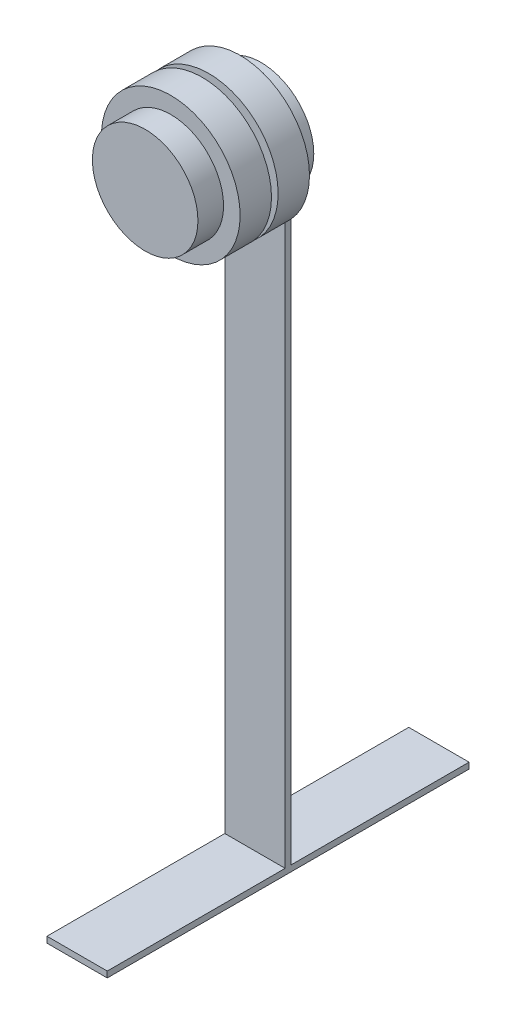
from build123d import *

# Parameters (mm, degrees)
SKETCH1_R                = 22.225
HUB_CENTER_DEPTH         = 25.4
HUB_CENTER_DEPTH_BACK    = 23.4
INNER_START              = 1.397
SKETCH2_R                = 29.21
INNER_BEARING_DEPTH      = 13.208
OUTER_START              = -1.397
SKETCH3_R                = 29.21
OUTER_BEARING_DEPTH      = 13.208
TIRE_ARM_DEPTH           = 2.54
SKETCH5_W                = 25.4
SKETCH5_H                = 152.4
TIRE_CONTACT_PATCH_DEPTH = 2.54


with BuildPart() as part:
    # Sketch1 → Hub Center (new body, two sides)
    with BuildSketch(Plane.XY) as hub_center_sk:
        Circle(SKETCH1_R)
    extrude(amount=HUB_CENTER_DEPTH)
    extrude(hub_center_sk.sketch, amount=-HUB_CENTER_DEPTH_BACK)

    # Sketch2 → Inner Bearing (add)
    with BuildSketch(Plane.XY.offset(INNER_START)):
        Circle(SKETCH2_R)
    extrude(amount=INNER_BEARING_DEPTH)

    # Sketch3 → Outer Bearing (add)
    with BuildSketch(Plane.XY.offset(OUTER_START)):
        Circle(SKETCH3_R)
    extrude(amount=-OUTER_BEARING_DEPTH)

    # Sketch4 → Tire Arm (add)
    with BuildSketch(Plane(origin=(0, 0, -23.4), x_dir=(-1, 0, 0), z_dir=(0, 0, -1))):
        with BuildLine():
            Line((-12.7, -18.238986403), (-12.7, -266.7))
            Line((-12.7, -266.7), (12.7, -266.7))
            Line((12.7, -266.7), (12.7, -18.238986403))
            ThreePointArc((12.7, -18.238986403), (0, -22.225), (-12.7, -18.238986403))
        make_face()
    extrude(amount=-TIRE_ARM_DEPTH)

    # Sketch5 → Tire Contact Patch (add)
    with BuildSketch(Plane.XZ.offset(266.7)):
        with Locations((0, -22.13)):
            Rectangle(SKETCH5_W, SKETCH5_H)
    extrude(amount=-TIRE_CONTACT_PATCH_DEPTH)


solid = part.part
